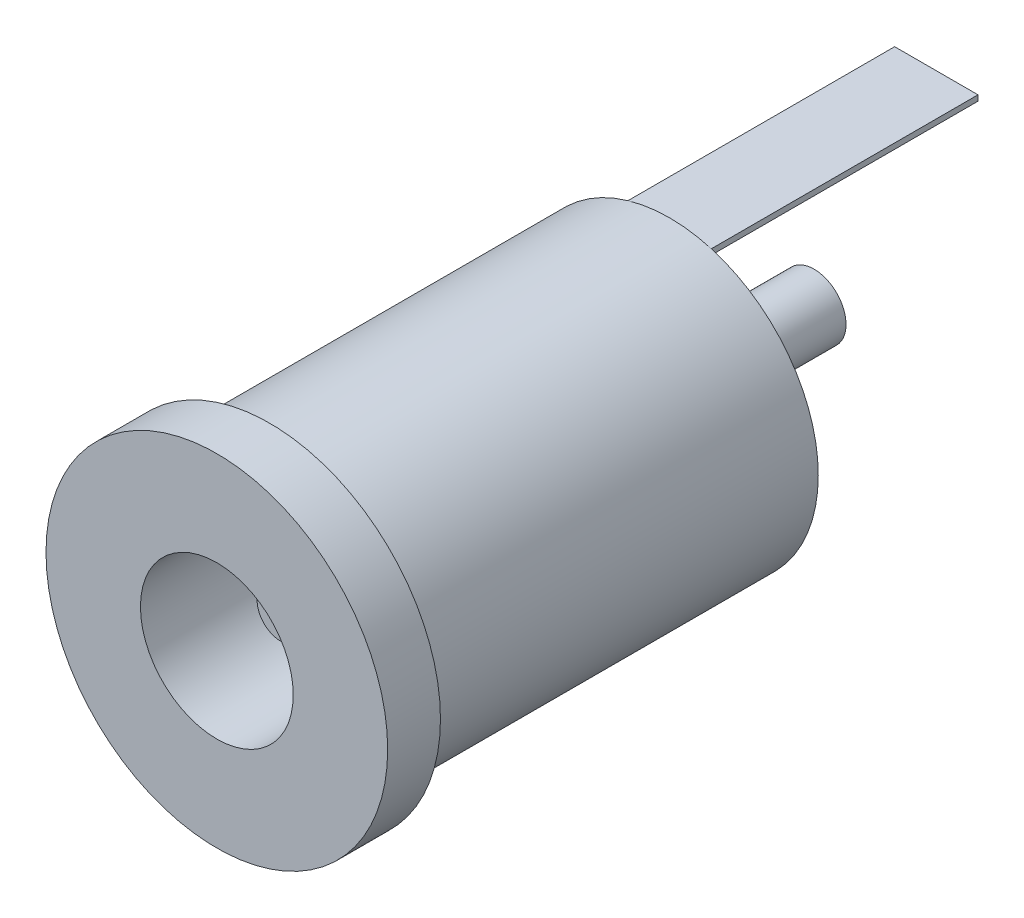
from build123d import *

# Parameters (mm, degrees)
SKETCH1_R           = 6.15
SKETCH1_R_2         = 2.75
BOSS_EXTRUDE1_DEPTH = 1.9
BOSS_EXTRUDE2_START = -14.4
SKETCH1_3_R         = 5.35
SKETCH1_3_R_2       = 2.75
BOSS_EXTRUDE2_DEPTH = 14.4
SKETCH2_R           = 2.75
BOSS_EXTRUDE3_DEPTH = 3
SKETCH2_3_R         = 1.9
BOSS_EXTRUDE4_DEPTH = 0.8
SKETCH2_5_R         = 0.85
BOSS_EXTRUDE5_DEPTH = 14
SKETCH2_6_R         = 1.15
BOSS_EXTRUDE6_DEPTH = 5.2
SKETCH2_7_W         = 3
SKETCH2_7_H         = 0.2
BOSS_EXTRUDE7_DEPTH = 9.6


with BuildPart() as part:
    # Sketch1 → Boss-Extrude1 (new body)
    with BuildSketch(Plane.XY):
        Circle(SKETCH1_R)
        Circle(SKETCH1_R_2, mode=Mode.SUBTRACT)
    extrude(amount=BOSS_EXTRUDE1_DEPTH)

    # Sketch1_3 → Boss-Extrude2 (add)
    with BuildSketch(Plane.XY.offset(BOSS_EXTRUDE2_START)):
        Circle(SKETCH1_3_R)
        Circle(SKETCH1_3_R_2, mode=Mode.SUBTRACT)
    extrude(amount=BOSS_EXTRUDE2_DEPTH)

    # Sketch2 → Boss-Extrude3 (add)
    with BuildSketch(Plane(origin=(0, 0, -14.4), x_dir=(-1, 0, 0), z_dir=(0, 0, -1))):
        Circle(SKETCH2_R)
    extrude(amount=-BOSS_EXTRUDE3_DEPTH)

    # Sketch2_3 → Boss-Extrude4 (add)
    with BuildSketch(Plane(origin=(0, 0, -14.4), x_dir=(-1, 0, 0), z_dir=(0, 0, -1))):
        Circle(SKETCH2_3_R)
    extrude(amount=BOSS_EXTRUDE4_DEPTH)

    # Sketch2_5 → Boss-Extrude5 (add)
    with BuildSketch(Plane(origin=(0, 0, -14.4), x_dir=(-1, 0, 0), z_dir=(0, 0, -1))):
        Circle(SKETCH2_5_R)
    extrude(amount=-BOSS_EXTRUDE5_DEPTH)

    # Sketch2_6 → Boss-Extrude6 (add)
    with BuildSketch(Plane(origin=(0, 0, -14.4), x_dir=(-1, 0, 0), z_dir=(0, 0, -1))):
        Circle(SKETCH2_6_R)
    extrude(amount=BOSS_EXTRUDE6_DEPTH)

    # Sketch2_7 → Boss-Extrude7 (add)
    with BuildSketch(Plane(origin=(0, 0, -14.4), x_dir=(-1, 0, 0), z_dir=(0, 0, -1))):
        with Locations((0, 5.035416244)):
            Rectangle(SKETCH2_7_W, SKETCH2_7_H)
    extrude(amount=BOSS_EXTRUDE7_DEPTH)


solid = part.part
